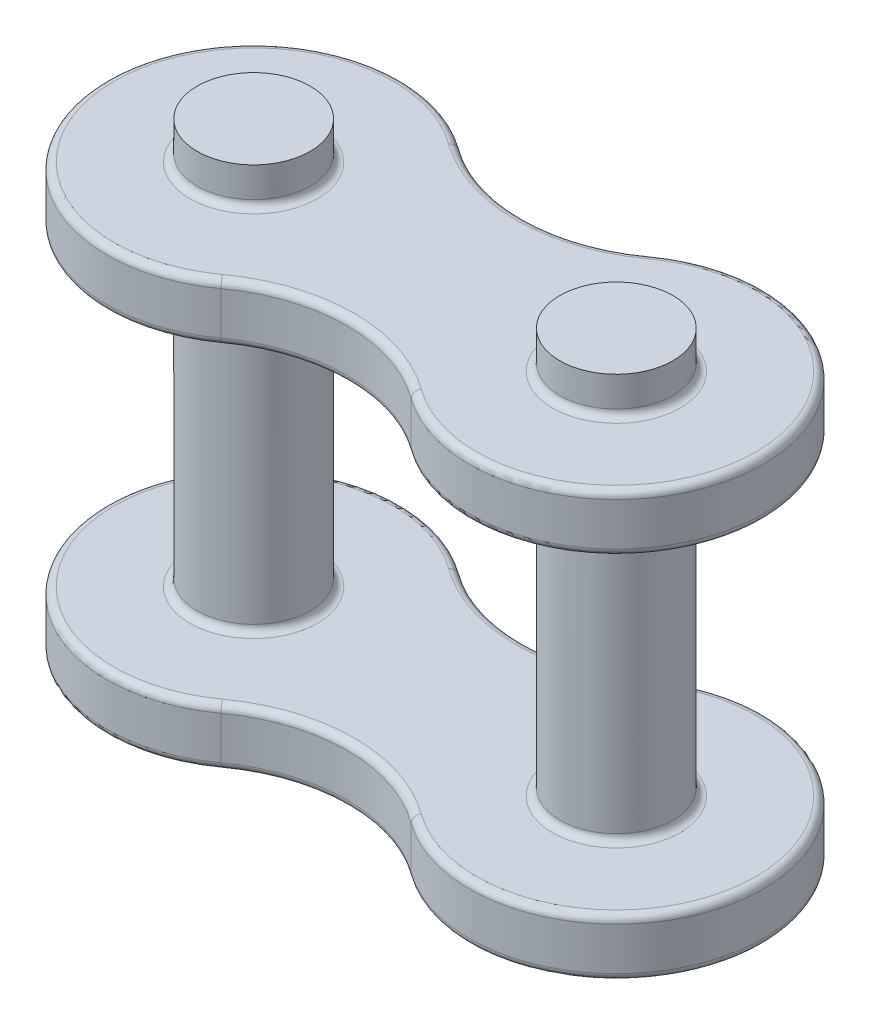
from build123d import *

# Parameters (mm, degrees)
SKETCH2_R            = 1.98
BOSS_EXTRUDE1_DEPTH  = 1.0033
SKETCH5_R            = 1.98
BOSS_EXTRUDE2_DEPTH  = 8.7503
FILLET1_R            = 0.254
FILLET1_OF_MIRROR1_R = 0.254


with BuildPart() as part:
    # Sketch2 → Boss-Extrude1 (new body, symmetric)
    with BuildSketch(Plane(origin=(0, 0, 0), x_dir=(1, 0, 0), z_dir=(0, 1, 0))):
        with BuildLine():
            ThreePointArc((-3.329269201, 4.163025065), (-11.4935, 0), (-3.329269201, -4.163025065))
            ThreePointArc((-3.329269201, -4.163025065), (0, -3.082404108), (3.329269201, -4.163025065))
            ThreePointArc((3.329269201, -4.163025065), (11.4935, 0), (3.329269201, 4.163025065))
            ThreePointArc((3.329269201, 4.163025065), (0, 3.082404108), (-3.329269201, 4.163025065))
        make_face()
        with Locations((-6.35, 0)):
            Circle(SKETCH2_R, mode=Mode.SUBTRACT)
        with Locations((6.35, 0)):
            Circle(SKETCH2_R, mode=Mode.SUBTRACT)
    boss_extrude1 = extrude(amount=BOSS_EXTRUDE1_DEPTH, both=True)

    # Sketch5 → Boss-Extrude2 (add, symmetric)
    with BuildSketch(Plane(origin=(0, 6.4389, 0), x_dir=(1, 0, 0), z_dir=(0, 1, 0))):
        with Locations((-6.35, 0)):
            Circle(SKETCH5_R)
        with Locations((6.35, 0)):
            Circle(SKETCH5_R)
    extrude(amount=BOSS_EXTRUDE2_DEPTH, both=True)

    # Fillet1
    fillet1_edges = [part.edges().sort_by_distance(p)[0] for p in [
        (-8.33, 1.0033, 0),
        (0, 1.0033, 3.082404108),
        (4.37, 1.0033, 0),
        (11.4935, 1.0033, 0),
        (-8.33, -1.0033, 0),
        (4.37, -1.0033, 0),
        (0, 1.0033, -3.082404108),
        (11.4935, -1.0033, 0),
        (0, -1.0033, 3.082404108),
        (-11.4935, -1.0033, 0),
        (0, -1.0033, -3.082404108),
        (-11.4935, 1.0033, 0),
    ]]
    fillet(fillet1_edges, radius=FILLET1_R)

    # Mirror1: Boss-Extrude1 across plane
    add(boss_extrude1.mirror(Plane.ZX.offset(6.4389)))

    # Fillet1 of Mirror1
    fillet1_of_mirror1_edges = [part.edges().sort_by_distance(p)[0] for p in [
        (-8.33, 11.8745, 0),
        (0, 11.8745, 3.082404108),
        (4.37, 11.8745, 0),
        (11.4935, 11.8745, 0),
        (-8.33, 13.8811, 0),
        (4.37, 13.8811, 0),
        (0, 11.8745, -3.082404108),
        (11.4935, 13.8811, 0),
        (0, 13.8811, 3.082404108),
        (-11.4935, 13.8811, 0),
        (0, 13.8811, -3.082404108),
        (-11.4935, 11.8745, 0),
    ]]
    fillet(fillet1_of_mirror1_edges, radius=FILLET1_OF_MIRROR1_R)


solid = part.part
